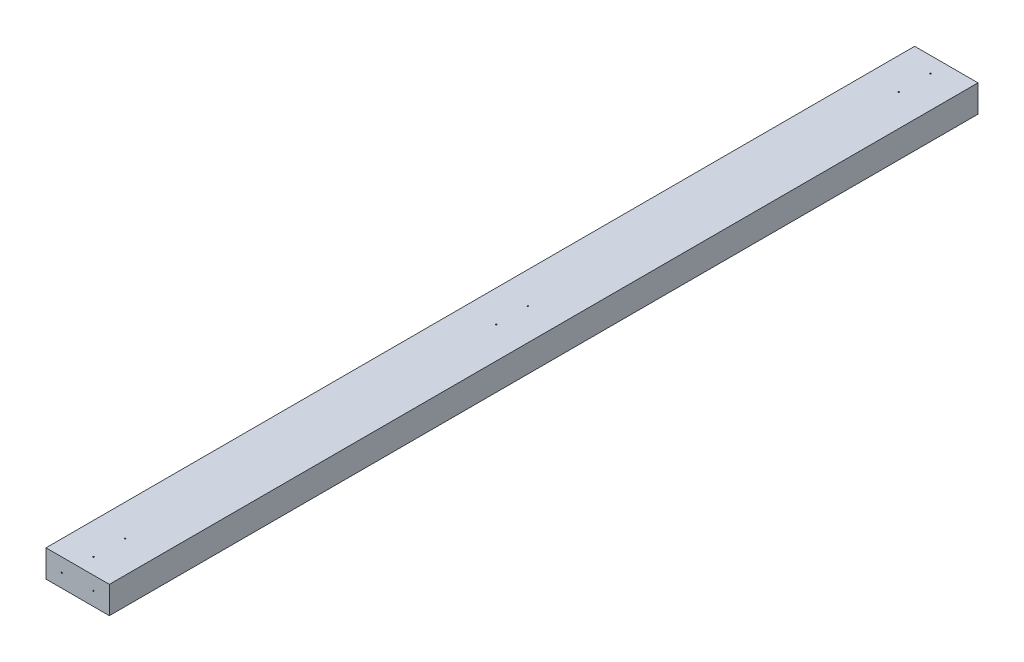
from build123d import *

# Parameters (mm, degrees)
SKETCH1_W           = 88.9
SKETCH1_H           = 38.1
BOSS_EXTRUDE1_DEPTH = 1219.2
SKETCH2_R           = 0.8763
CUT_EXTRUDE1_DEPTH  = 1219.2
SKETCH3_R           = 0.8763
CUT_EXTRUDE2_DEPTH  = 38.1


with BuildPart() as part:
    # Sketch1 → Boss-Extrude1 (new body)
    with BuildSketch(Plane.XY):
        with Locations((44.45, 19.05)):
            Rectangle(SKETCH1_W, SKETCH1_H)
    extrude(amount=BOSS_EXTRUDE1_DEPTH)

    # Sketch2 → Cut-Extrude1 (cut)
    with BuildSketch(Plane(origin=(0, 0, 0), x_dir=(-1, 0, 0), z_dir=(0, 0, -1))):
        with Locations((-66.675, 19.05)):
            Circle(SKETCH2_R)
        with Locations((-22.225, 19.05)):
            Circle(SKETCH2_R)
    extrude(amount=-CUT_EXTRUDE1_DEPTH, mode=Mode.SUBTRACT)

    # Sketch3 → Cut-Extrude2 (cut)
    with BuildSketch(Plane.XZ):
        with Locations((44.45, 1196.975)):
            Circle(SKETCH3_R)
        with Locations((44.45, 1152.525)):
            Circle(SKETCH3_R)
        with Locations((44.45, 22.225)):
            Circle(SKETCH3_R)
        with Locations((44.45, 66.675)):
            Circle(SKETCH3_R)
        with Locations((44.45, 587.375)):
            Circle(SKETCH3_R)
        with Locations((44.45, 631.825)):
            Circle(SKETCH3_R)
    extrude(amount=-CUT_EXTRUDE2_DEPTH, mode=Mode.SUBTRACT)


solid = part.part
